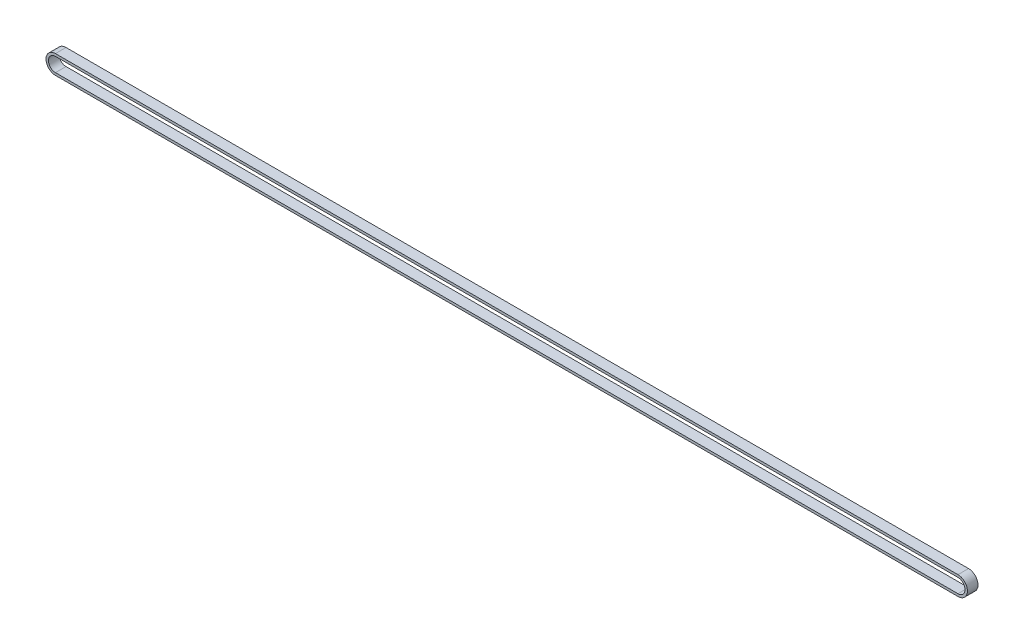
from build123d import *

# Parameters (mm, degrees)
BOSS_EXTRUDE1_DEPTH = 6


with BuildPart() as part:
    # Sketch1 → Boss-Extrude1 (new body)
    with BuildSketch(Plane.XY):
        with BuildLine():
            Line((-256.5, 5.38), (256.5, 5.38))
            ThreePointArc((256.5, 5.38), (261.88, 0), (256.5, -5.38))
            Line((256.5, -5.38), (-256.5, -5.38))
            ThreePointArc((-256.5, -5.38), (-261.88, 0), (-256.5, 5.38))
        make_face()
        with BuildLine():
            Line((-256.5, -4), (256.5, -4))
            ThreePointArc((256.5, -4), (260.5, 0), (256.5, 4))
            Line((256.5, 4), (-256.5, 4))
            ThreePointArc((-256.5, 4), (-260.5, 0), (-256.5, -4))
        make_face(mode=Mode.SUBTRACT)
    extrude(amount=BOSS_EXTRUDE1_DEPTH)


solid = part.part
